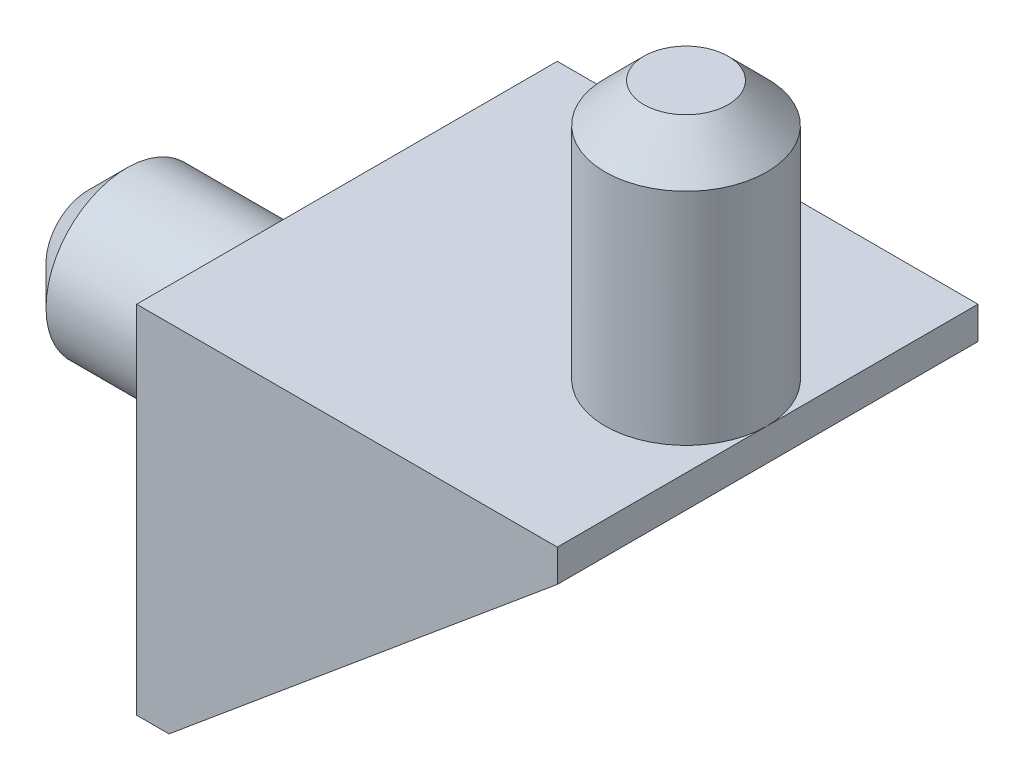
from build123d import *

# Parameters (mm, degrees)
SKETCH1_W           = 12
SKETCH1_H           = 11
BOSS_EXTRUDE1_DEPTH = 1
SKETCH2_W           = 11
SKETCH2_H           = 11
BOSS_EXTRUDE2_DEPTH = 1
SKETCH3_R           = 2.5
BOSS_EXTRUDE3_DEPTH = 8
CHAMFER1_SIZE       = 1.2
SKETCH4_R           = 2.5
BOSS_EXTRUDE4_DEPTH = 8
CHAMFER2_SIZE       = 1.2
BOSS_EXTRUDE5_DEPTH = 1
BOSS_EXTRUDE6_DEPTH = 1


with BuildPart() as part:
    # Sketch1 → Boss-Extrude1 (new body)
    with BuildSketch(Plane(origin=(0, 0, 0), x_dir=(1, 0, 0), z_dir=(0, 1, 0))):
        with Locations((6, -5.5)):
            Rectangle(SKETCH1_W, SKETCH1_H)
    extrude(amount=BOSS_EXTRUDE1_DEPTH)

    # Sketch2 → Boss-Extrude2 (add)
    with BuildSketch(Plane.ZY):
        with Locations((5.5, -4.5)):
            Rectangle(SKETCH2_W, SKETCH2_H)
    extrude(amount=BOSS_EXTRUDE2_DEPTH)

    # Sketch3 → Boss-Extrude3 (add)
    with BuildSketch(Plane.ZY.offset(1)):
        with Locations((5.5, -4.5)):
            Circle(SKETCH3_R)
    extrude(amount=BOSS_EXTRUDE3_DEPTH)

    # Chamfer1
    chamfer1_edges = [part.edges().sort_by_distance(p)[0] for p in [
        (-9, -4.5, 3),
    ]]
    chamfer(chamfer1_edges, length=CHAMFER1_SIZE)

    # Sketch4 → Boss-Extrude4 (add)
    with BuildSketch(Plane(origin=(0, 1, 0), x_dir=(1, 0, 0), z_dir=(0, 1, 0))):
        with Locations((9.5, -5.523022779)):
            Circle(SKETCH4_R)
    extrude(amount=BOSS_EXTRUDE4_DEPTH)

    # Chamfer2
    chamfer2_edges = [part.edges().sort_by_distance(p)[0] for p in [
        (7, 9, 5.523022779),
    ]]
    chamfer(chamfer2_edges, length=CHAMFER2_SIZE)

    # Sketch5 → Boss-Extrude5 (add)
    with BuildSketch(Plane.XY.offset(11)):
        Polygon((0, -10), (12, 0), (12, 1), (-1, 1), (-1, -10), align=None)
    extrude(amount=BOSS_EXTRUDE5_DEPTH)

    # Sketch6 → Boss-Extrude6 (add)
    with BuildSketch(Plane(origin=(0, 0, 0), x_dir=(-1, 0, 0), z_dir=(0, 0, -1))):
        Polygon((-12, 0), (0, -10), (1, -10), (1, 1), (-12, 1), align=None)
    extrude(amount=BOSS_EXTRUDE6_DEPTH)


solid = part.part
